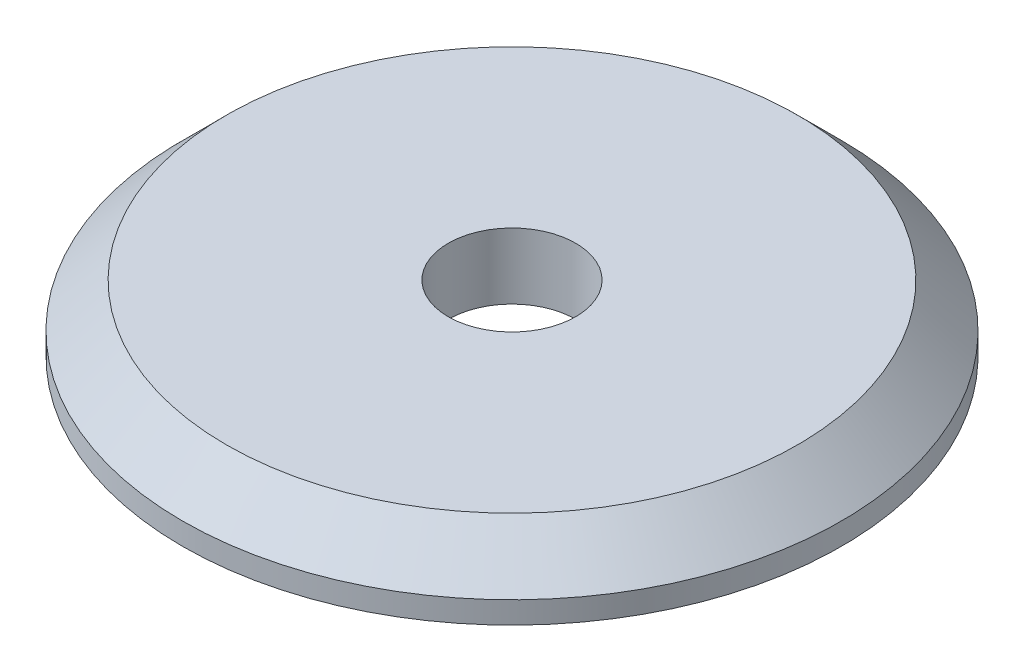
from build123d import *

# Parameters (mm, degrees)
SKETCH1_R                = 15
BOSS_EXTRUDE1_DEPTH      = 3
CHAMFER1_SIZE            = 2
M5_CLEARANCE_HOLE1_D     = 5.8
M5_CLEARANCE_HOLE1_DEPTH = 6
M5_CLEARANCE_HOLE1_TIP   = 1.742495795


with BuildPart() as part:
    # Sketch1 → Boss-Extrude1 (new body)
    with BuildSketch(Plane(origin=(0, 0, 0), x_dir=(1, 0, 0), z_dir=(0, 1, 0))):
        Circle(SKETCH1_R)
    extrude(amount=BOSS_EXTRUDE1_DEPTH)

    # Chamfer1
    chamfer1_edges = [part.edges().sort_by_distance(p)[0] for p in [
        (-15, 3, 0),
    ]]
    chamfer(chamfer1_edges, length=CHAMFER1_SIZE)

    # M5 Clearance Hole1
    with Locations(Plane(origin=(0, 3, 0), x_dir=(1, 0, 0), z_dir=(0, 1, 0))):
        with Locations((0, 0)):
            Hole(M5_CLEARANCE_HOLE1_D / 2, depth=M5_CLEARANCE_HOLE1_DEPTH)
            with Locations((0, 0, -(M5_CLEARANCE_HOLE1_DEPTH + M5_CLEARANCE_HOLE1_TIP / 2))):  # 118° drill point
                Cone(0, M5_CLEARANCE_HOLE1_D / 2, M5_CLEARANCE_HOLE1_TIP, mode=Mode.SUBTRACT)


solid = part.part
